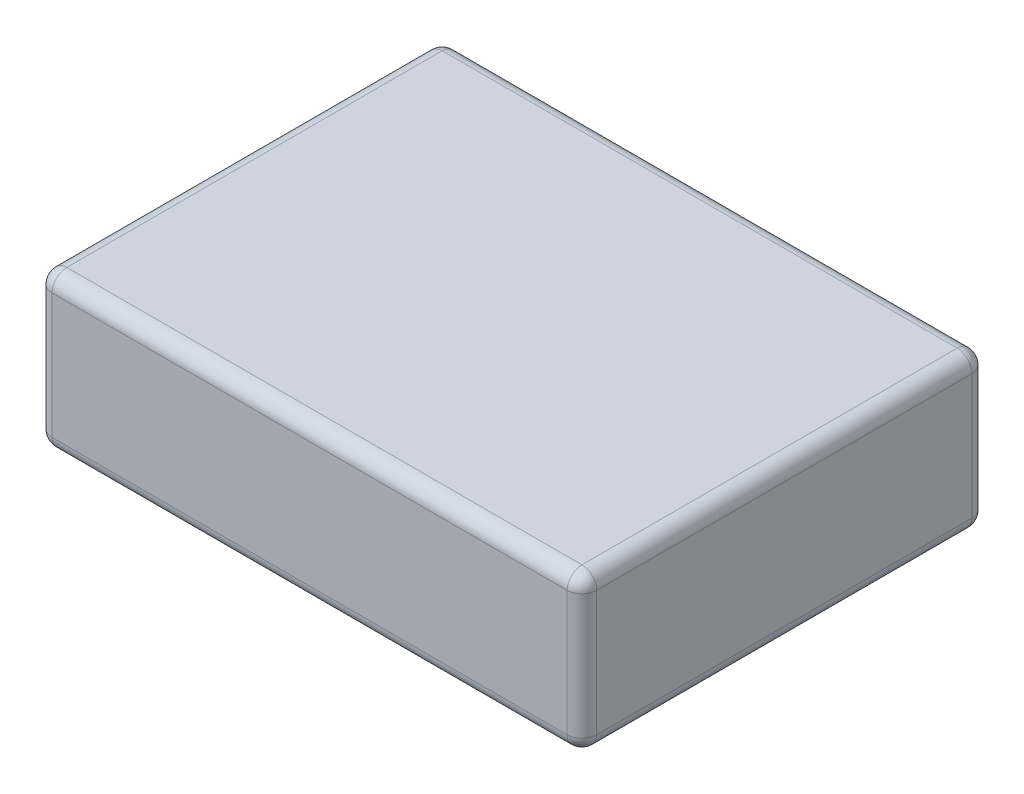
from build123d import *

# Parameters (mm, degrees)
SKETCH1_W           = 93.98
SKETCH1_H           = 69.85
BOSS_EXTRUDE1_DEPTH = 26.67
FILLET1_R           = 2.54


with BuildPart() as part:
    # Sketch1 → Boss-Extrude1 (new body)
    with BuildSketch(Plane(origin=(0, 0, 0), x_dir=(1, 0, 0), z_dir=(0, 1, 0))):
        with Locations((46.99, 34.925)):
            Rectangle(SKETCH1_W, SKETCH1_H)
    extrude(amount=BOSS_EXTRUDE1_DEPTH)

    # Fillet1
    fillet1_edges = [part.edges().sort_by_distance(p)[0] for p in [
        (93.98, 26.67, -34.925),
        (46.99, 26.67, -69.85),
        (0, 26.67, -34.925),
        (46.99, 0, -69.85),
        (93.98, 0, -34.925),
        (46.99, 0, 0),
        (0, 0, -34.925),
        (46.99, 26.67, 0),
        (0, 13.335, -69.85),
        (93.98, 13.335, -69.85),
        (93.98, 13.335, 0),
        (0, 13.335, 0),
    ]]
    fillet(fillet1_edges, radius=FILLET1_R)


solid = part.part
